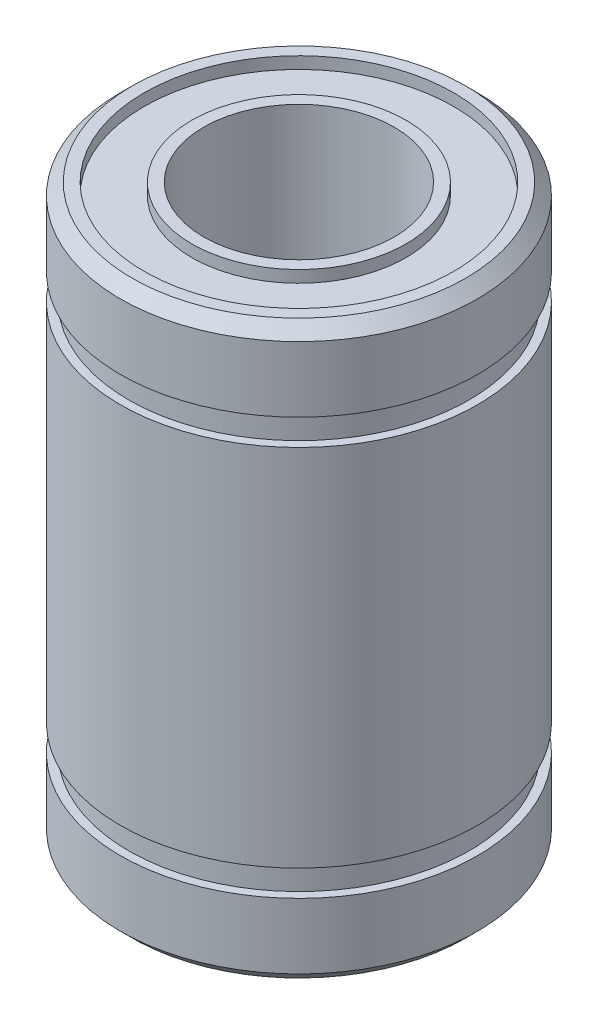
from build123d import *

# Parameters (mm, degrees)
SKETCH2_R          = 6.5
SKETCH2_R_2        = 4.5
CUT_EXTRUDE1_DEPTH = 0.5


with BuildPart() as part:
    # Sketch1 → Body (revolve)
    with BuildSketch(Plane.XY):
        Polygon((4, -12), (4, 12), (7, 12), (7.5, 11.5), (7.5, 8.75), (7.15, 8.75), (7.15, 7.65), (7.5, 7.65), (7.5, -7.65), (7.15, -7.65), (7.15, -8.75), (7.5, -8.75), (7.5, -11.5), (7, -12), align=None)
    revolve(axis=Axis((0, 12, 0), (0, -1, 0)))

    # Sketch2 → Cut-Extrude1 (cut)
    with BuildSketch(Plane(origin=(0, 12, 0), x_dir=(1, 0, 0), z_dir=(0, 1, 0))):
        Circle(SKETCH2_R)
        Circle(SKETCH2_R_2, mode=Mode.SUBTRACT)
    cut_extrude1 = extrude(amount=-CUT_EXTRUDE1_DEPTH, mode=Mode.SUBTRACT)

    # Mirror1: Cut-Extrude1 across plane
    add(cut_extrude1.mirror(Plane.ZX), mode=Mode.SUBTRACT)


solid = part.part
